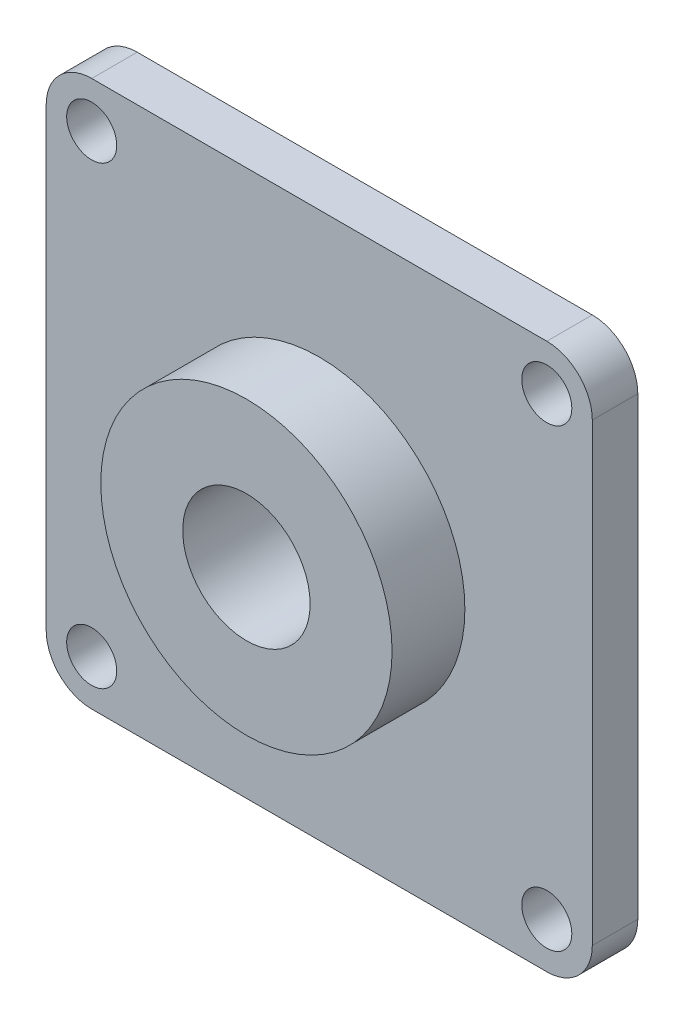
from build123d import *

# Parameters (mm, degrees)
SKETCH1_W           = 60
SKETCH1_H           = 60
BOSS_EXTRUDE1_DEPTH = 5
SKETCH2_R           = 2.75
CUT_EXTRUDE1_DEPTH  = 5
FILLET1_R           = 5
SKETCH3_R           = 16
BOSS_EXTRUDE2_DEPTH = 8
SKETCH4_R           = 7
CUT_EXTRUDE2_DEPTH  = 14


with BuildPart() as part:
    # Sketch1 → Boss-Extrude1 (new body)
    with BuildSketch(Plane.XY):
        Rectangle(SKETCH1_W, SKETCH1_H)
    extrude(amount=BOSS_EXTRUDE1_DEPTH)

    # Sketch2 → Cut-Extrude1 (cut)
    with BuildSketch(Plane.XY.offset(5)):
        with Locations((-25, 25)):
            Circle(SKETCH2_R)
        with Locations((25, 25)):
            Circle(SKETCH2_R)
        with Locations((25, -25)):
            Circle(SKETCH2_R)
        with Locations((-25, -25)):
            Circle(SKETCH2_R)
    extrude(amount=-CUT_EXTRUDE1_DEPTH, mode=Mode.SUBTRACT)

    # Fillet1
    fillet1_edges = [part.edges().sort_by_distance(p)[0] for p in [
        (-30, 30, 2.5),
        (30, 30, 2.5),
        (30, -30, 2.5),
        (-30, -30, 2.5),
    ]]
    fillet(fillet1_edges, radius=FILLET1_R)

    # Sketch3 → Boss-Extrude2 (add)
    with BuildSketch(Plane.XY.offset(5)):
        Circle(SKETCH3_R)
    extrude(amount=BOSS_EXTRUDE2_DEPTH)

    # Sketch4 → Cut-Extrude2 (cut, through all)
    with BuildSketch(Plane.XY.offset(13)):
        Circle(SKETCH4_R)
    extrude(amount=-CUT_EXTRUDE2_DEPTH, mode=Mode.SUBTRACT)


solid = part.part
